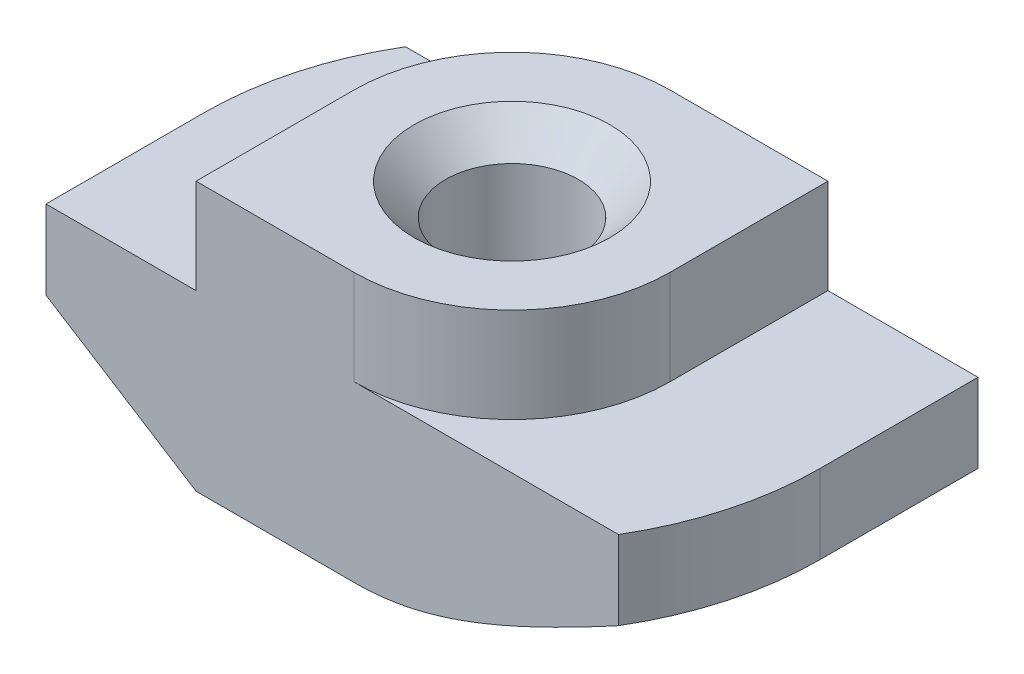
from build123d import *

# Parameters (mm, degrees)
EXTRUDE_1_DEPTH     = 5
CUT_EXTRUDE_1_DEPTH = 3
CUT_EXTRUDE_2_DEPTH = 6.5


with BuildPart() as part:
    # Эскиз1 → Бобышка-Вытянуть1 (new body, symmetric)
    with BuildSketch(Plane.XY):
        Polygon((5, 0), (-5, 0), (-5, -3), (-9.75, -3), (-9.75, -8.5), (9.75, -8.5), (9.75, -3), (5, -3), align=None)
    extrude(amount=EXTRUDE_1_DEPTH, both=True)

    # Эскиз3 → Отверстие обработанное метчиком M51 (revolve, cut)
    with BuildSketch(Plane(origin=(0, 0, 0), x_dir=(0, 0, 1), z_dir=(1, 0, 0))):
        Polygon((0, 0), (0, 8.5), (3.1, 8.5), (2.1, 7.5), (2.1, 1), (3.1, 0), align=None)
    revolve(axis=Axis((0, 6.35, 0), (0, -1, 0)), mode=Mode.SUBTRACT)

    # Эскиз4 → Вырез-Вытянуть1 (cut)
    with BuildSketch(Plane(origin=(0, 0, 0), x_dir=(1, 0, 0), z_dir=(0, 1, 0))):
        with BuildLine():
            Line((-5, 5), (-5, 0))
            ThreePointArc((-5, 0), (-3.535533906, 3.535533906), (0, 5))
            Line((0, 5), (-5, 5))
        make_face()
        with BuildLine():
            Line((0, -5), (5, -5))
            Line((5, -5), (5, 0))
            ThreePointArc((5, 0), (3.535533906, -3.535533906), (0, -5))
        make_face()
    extrude(amount=-CUT_EXTRUDE_1_DEPTH, mode=Mode.SUBTRACT)

    # Эскиз5 → Вырез-Вытянуть2 (cut, through all)
    with BuildSketch(Plane(origin=(0, -3, 0), x_dir=(1, 0, 0), z_dir=(0, 1, 0))):
        with BuildLine():
            Line((-9.75, 0), (-9.75, 5))
            Line((-9.75, 5), (-8.370334521, 5))
            ThreePointArc((-8.370334521, 5), (-9.398756875, 2.59342808), (-9.75, 0))
        make_face()
        with BuildLine():
            Line((9.75, 0), (9.75, -5))
            Line((9.75, -5), (8.370334521, -5))
            ThreePointArc((8.370334521, -5), (9.398756875, -2.59342808), (9.75, 0))
        make_face()
    extrude(amount=-CUT_EXTRUDE_2_DEPTH, mode=Mode.SUBTRACT)

    # Вырез-По траектории1: sweep along a path in Эскиз7
    with BuildLine(Plane.XZ.offset(8.5)) as sweep_1_path:
        Line((0, 9.75), (-9.75, 9.75))
        Line((-9.75, 9.75), (-9.75, 0))
        ThreePointArc((-9.75, 0), (-6.894291117, -6.894291117), (0, -9.75))
        Line((0, -9.75), (9.75, -9.75))
        Line((9.75, -9.75), (9.75, 0))
        ThreePointArc((9.75, 0), (6.894291117, 6.894291117), (0, 9.75))
    # Эскиз6 → Вырез-По траектории1 (sweep, cut)
    with BuildSketch(Plane.XY.offset(5)):
        Polygon((-9.75, -5.5), (-9.75, -8.5), (-5, -8.5), align=None)
    sweep(path=sweep_1_path.line, transition=Transition.RIGHT, mode=Mode.SUBTRACT)


solid = part.part
